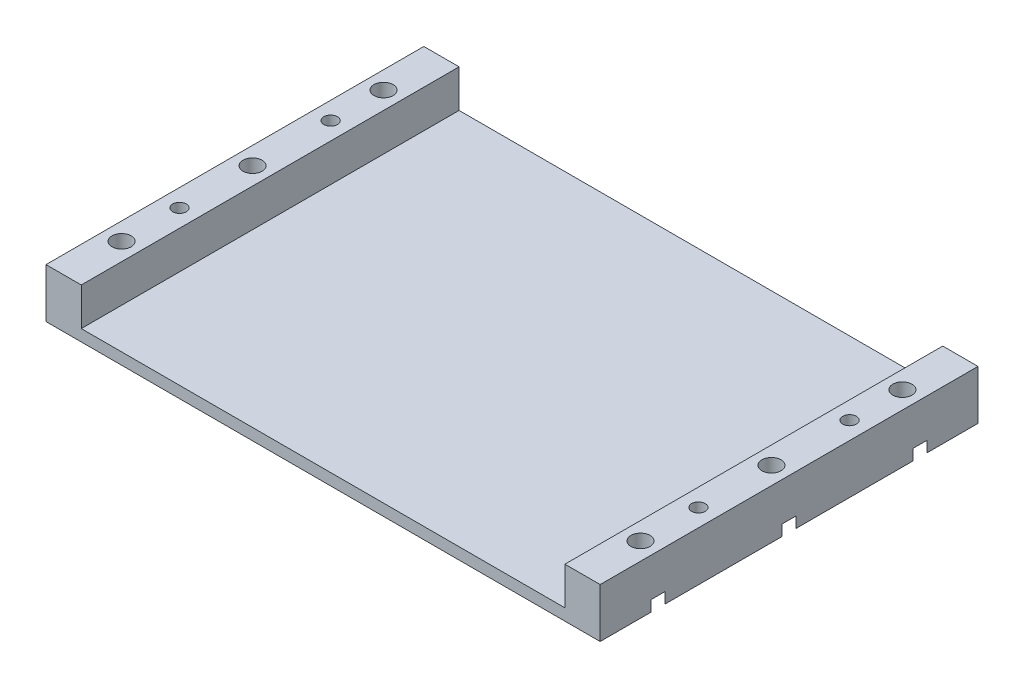
from build123d import *

# Parameters (mm, degrees)
SKETCH1_W                                      = 96
SKETCH1_H                                      = 75
BOSS_EXTRUDE1_DEPTH                            = 2.3
SKETCH2_W                                      = 7
SKETCH2_H                                      = 75
BOSS_EXTRUDE2_DEPTH                            = 7.5
BOSS_EXTRUDE2_DEPTH_BACK                       = 2.3
BOSS_EXTRUDE3_REACH                            = 9.5
SKETCH3_W                                      = 7
SKETCH3_H                                      = 75
BOSS_EXTRUDE3_DIRECTION_2_REACH                = 4.3
F_6_32_TAPPED_HOLE1_D                          = 2.7051
F_6_32_TAPPED_HOLE1_CBORE_D                    = 3.5052
F_6_32_TAPPED_HOLE1_CBORE_DEPTH                = 7.01
CBORE_FOR_6_BUTTON_HEAD_CAP_SCREW1_D           = 3.7973
CBORE_FOR_6_BUTTON_HEAD_CAP_SCREW1_CBORE_D     = 7.54126
CBORE_FOR_6_BUTTON_HEAD_CAP_SCREW1_CBORE_DEPTH = 2.1541994


with BuildPart() as part:
    # Sketch1 → Boss-Extrude1 (new body)
    with BuildSketch(Plane(origin=(0, 0, 0), x_dir=(1, 0, 0), z_dir=(0, 1, 0))):
        with Locations((48, 37.5)):
            Rectangle(SKETCH1_W, SKETCH1_H)
    extrude(amount=BOSS_EXTRUDE1_DEPTH)

    # Sketch2 → Boss-Extrude2 (add, two sides)
    with BuildSketch(Plane(origin=(0, 2.3, 0), x_dir=(1, 0, 0), z_dir=(0, 1, 0))) as boss_extrude2_sk:
        with Locations((-3.5, 37.5)):
            Rectangle(SKETCH2_W, SKETCH2_H)
    extrude(amount=BOSS_EXTRUDE2_DEPTH)
    extrude(boss_extrude2_sk.sketch, amount=-BOSS_EXTRUDE2_DEPTH_BACK)

    # Boss-Extrude3: up to this face of the body (flat: up to its plane)
    boss_extrude3_end = Plane(part.part.faces().sort_by_distance((-3.5, 9.8, -37.5))[0])
    # Sketch3 → Boss-Extrude3 (add, up to the picked face)
    with BuildSketch(Plane(origin=(0, 2.3, 0), x_dir=(1, 0, 0), z_dir=(0, 1, 0)), mode=Mode.PRIVATE) as boss_extrude3_sk1:
        with Locations((99.5, 37.5)):
            Rectangle(SKETCH3_W, SKETCH3_H)
    boss_extrude3_tool1 = split(extrude(boss_extrude3_sk1.sketch, amount=BOSS_EXTRUDE3_REACH, mode=Mode.PRIVATE), bisect_by=boss_extrude3_end, keep=Keep.BOTH, mode=Mode.PRIVATE)
    add(boss_extrude3_tool1.solids().sort_by_distance((99.5, 2.3, -37.5))[0])

    # Boss-Extrude3 direction 2: up to this face of the body (flat: up to its plane)
    boss_extrude3_direction_2_end = Plane(part.part.faces().sort_by_distance((44.5, 0, -37.5))[0])
    # Sketch3 → Boss-Extrude3 direction 2 (add, up to the picked face)
    with BuildSketch(Plane(origin=(0, 2.3, 0), x_dir=(1, 0, 0), z_dir=(0, 1, 0)), mode=Mode.PRIVATE) as boss_extrude3_direction_2_sk1:
        with Locations((99.5, 37.5)):
            Rectangle(SKETCH3_W, SKETCH3_H)
    boss_extrude3_direction_2_tool1 = split(extrude(boss_extrude3_direction_2_sk1.sketch, amount=-BOSS_EXTRUDE3_DIRECTION_2_REACH, mode=Mode.PRIVATE), bisect_by=boss_extrude3_direction_2_end, keep=Keep.BOTH, mode=Mode.PRIVATE)
    add(boss_extrude3_direction_2_tool1.solids().sort_by_distance((99.5, 2.3, -37.5))[0])

    # #6-32 Tapped Hole1 (through all)
    with Locations(Plane(origin=(0, 0, 0), x_dir=(-1, 0, 0), z_dir=(0, -1, 0))):
        with Locations((-99.5, 23), (-99.5, 53), (3.5, 23), (3.5, 53)):
            CounterBoreHole(F_6_32_TAPPED_HOLE1_D / 2, F_6_32_TAPPED_HOLE1_CBORE_D / 2, F_6_32_TAPPED_HOLE1_CBORE_DEPTH)

    # CBORE for #6 Button Head Cap Screw1 (through all)
    with Locations(Plane(origin=(0, 0, 0), x_dir=(-1, 0, 0), z_dir=(0, -1, 0))):
        with Locations((-99.5, 63.5), (-99.5, 37.5), (-99.5, 11.5), (3.5, 11.5), (3.5, 37.5), (3.5, 63.5)):
            CounterBoreHole(CBORE_FOR_6_BUTTON_HEAD_CAP_SCREW1_D / 2, CBORE_FOR_6_BUTTON_HEAD_CAP_SCREW1_CBORE_D / 2, CBORE_FOR_6_BUTTON_HEAD_CAP_SCREW1_CBORE_DEPTH)


solid = part.part
